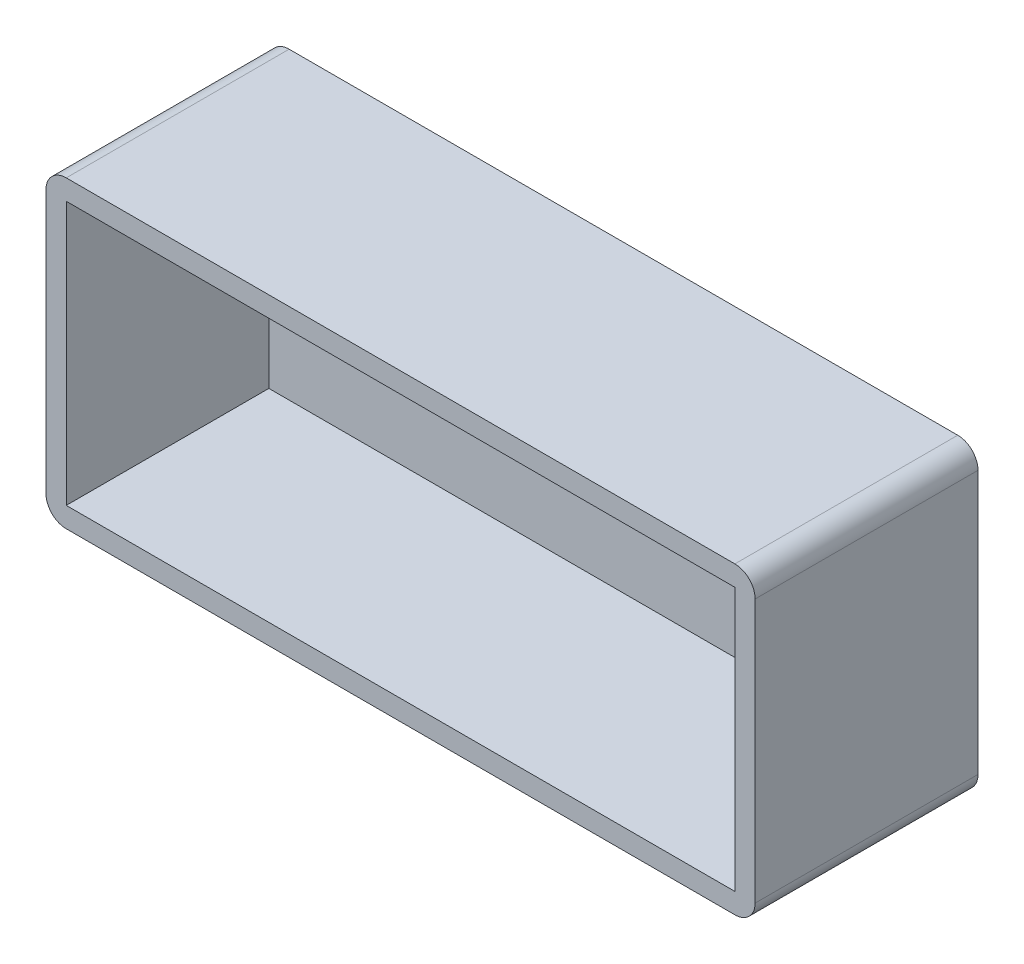
from build123d import *

# Parameters (mm, degrees)
CROQUIS1_W              = 70
CROQUIS1_H              = 30
SALIENTE_EXTRUIR4_DEPTH = 22
CROQUIS5_W              = 66
CROQUIS5_H              = 26
CORTAR_EXTRUIR1_DEPTH   = 20
CORTAR_EXTRUIR3_DEPTH   = 20
REDONDEO2_R             = 2
REDONDEO3_R             = 2
REDONDEO4_R             = 2
REDONDEO5_R             = 2


with BuildPart() as part:
    # Croquis1 → Saliente-Extruir4 (new body)
    with BuildSketch(Plane.XY):
        with Locations((35, 15)):
            Rectangle(CROQUIS1_W, CROQUIS1_H)
    extrude(amount=SALIENTE_EXTRUIR4_DEPTH)

    # Croquis5 → Cortar-Extruir1 (cut)
    with BuildSketch(Plane.XY.offset(22)):
        with Locations((35, 15)):
            Rectangle(CROQUIS5_W, CROQUIS5_H)
    extrude(amount=-CORTAR_EXTRUIR1_DEPTH, mode=Mode.SUBTRACT)

    # Croquis6 → Cortar-Extruir3 (cut)
    with BuildSketch(Plane.XY.offset(2)):
        with BuildLine():
            Line((10, 17), (24, 17))
            ThreePointArc((24, 17), (26, 15), (24, 13))
            Line((24, 13), (10, 13))
            ThreePointArc((10, 13), (8, 15), (10, 17))
        make_face()
        with BuildLine():
            Line((60, 17), (46, 17))
            ThreePointArc((46, 17), (44, 15), (46, 13))
            Line((46, 13), (60, 13))
            ThreePointArc((60, 13), (62, 15), (60, 17))
        make_face()
    extrude(amount=-CORTAR_EXTRUIR3_DEPTH, mode=Mode.SUBTRACT)

    # Redondeo2
    redondeo2_edges = [part.edges().sort_by_distance(p)[0] for p in [
        (70, 0, 11),
    ]]
    fillet(redondeo2_edges, radius=REDONDEO2_R)

    # Redondeo3
    redondeo3_edges = [part.edges().sort_by_distance(p)[0] for p in [
        (70, 30, 11),
    ]]
    fillet(redondeo3_edges, radius=REDONDEO3_R)

    # Redondeo4
    redondeo4_edges = [part.edges().sort_by_distance(p)[0] for p in [
        (0, 0, 11),
    ]]
    fillet(redondeo4_edges, radius=REDONDEO4_R)

    # Redondeo5
    redondeo5_edges = [part.edges().sort_by_distance(p)[0] for p in [
        (0, 30, 11),
    ]]
    fillet(redondeo5_edges, radius=REDONDEO5_R)


solid = part.part
